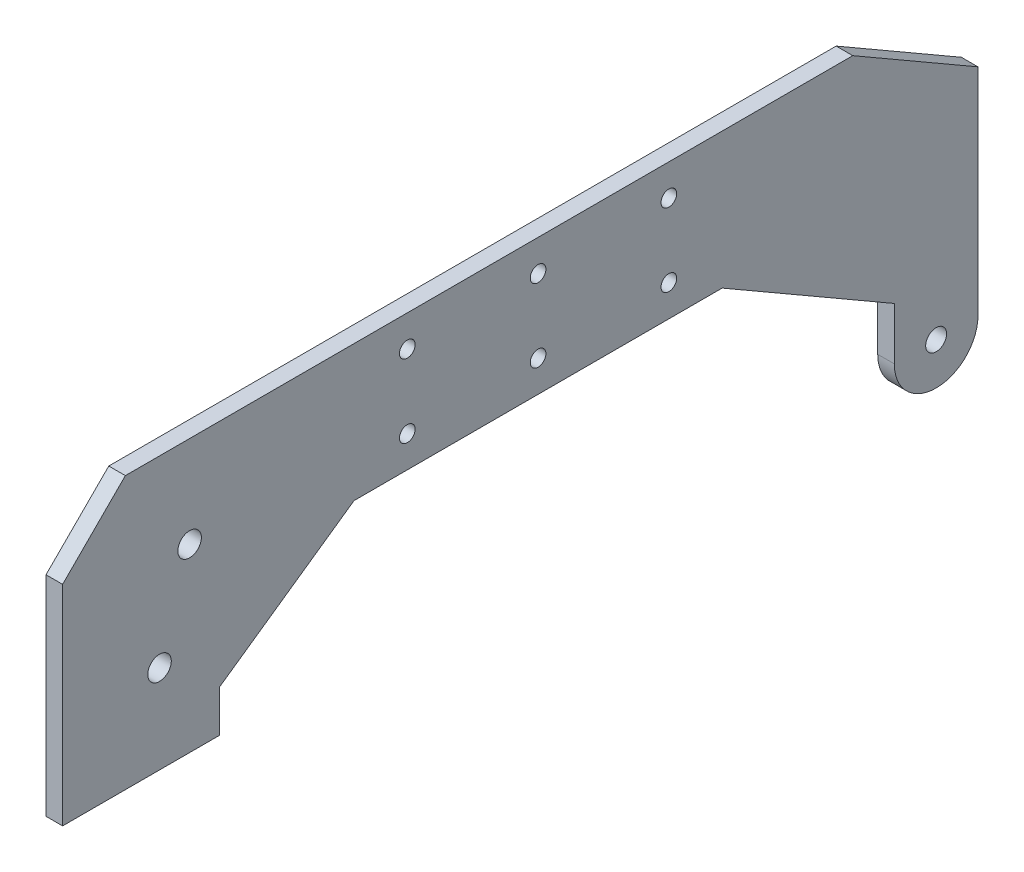
from build123d import *

# Parameters (mm, degrees)
SKETCH1_R           = 2
SKETCH1_R_2         = 1.5
SKETCH1_R_3         = 2.25
BOSS_EXTRUDE1_DEPTH = 3.175


with BuildPart() as part:
    # Sketch1 → Boss-Extrude1 (new body)
    with BuildSketch(Plane(origin=(0, 0, 0), x_dir=(0, 0, -1), z_dir=(1, 0, 0))):
        with BuildLine():
            Line((-384.128639271, 211.620810697), (-360.186352931, 197.797725233))
            Line((-360.186352931, 197.797725233), (-360.186352931, 156.620810697))
            ThreePointArc((-360.186352931, 156.620810697), (-368.186352931, 148.620810697), (-376.186352931, 156.620810697))
            Line((-376.186352931, 156.620810697), (-376.186352931, 166.620810697))
            Line((-376.186352931, 166.620810697), (-409.095318274, 185.620810697))
            Line((-409.095318274, 185.620810697), (-479.479688809, 185.620810697))
            Line((-479.479688809, 185.620810697), (-505.186352931, 167.620810697))
            Line((-505.186352931, 167.620810697), (-505.186352931, 159.620810697))
            Line((-505.186352931, 159.620810697), (-535.186352931, 159.620810697))
            Line((-535.186352931, 159.620810697), (-535.186352931, 199.620810697))
            Line((-535.186352931, 199.620810697), (-523.186352931, 211.620810697))
            Line((-523.186352931, 211.620810697), (-384.128639271, 211.620810697))
        make_face()
        with Locations((-368.186352931, 156.620810697)):
            Circle(SKETCH1_R, mode=Mode.SUBTRACT)
        with Locations((-419.287503542, 205.620810697)):
            Circle(SKETCH1_R_2, mode=Mode.SUBTRACT)
        with Locations((-510.908050144, 194.119148631)):
            Circle(SKETCH1_R_3, mode=Mode.SUBTRACT)
        with Locations((-516.656718986, 176.534985115)):
            Circle(SKETCH1_R_3, mode=Mode.SUBTRACT)
        with Locations((-419.287503542, 191.620810697)):
            Circle(SKETCH1_R_2, mode=Mode.SUBTRACT)
        with Locations((-469.287503542, 205.620810697)):
            Circle(SKETCH1_R_2, mode=Mode.SUBTRACT)
        with Locations((-469.287503542, 191.620810697)):
            Circle(SKETCH1_R_2, mode=Mode.SUBTRACT)
        with Locations((-444.287503542, 205.620810697)):
            Circle(SKETCH1_R_2, mode=Mode.SUBTRACT)
        with Locations((-444.287503542, 191.620810697)):
            Circle(SKETCH1_R_2, mode=Mode.SUBTRACT)
    extrude(amount=BOSS_EXTRUDE1_DEPTH)


solid = part.part
